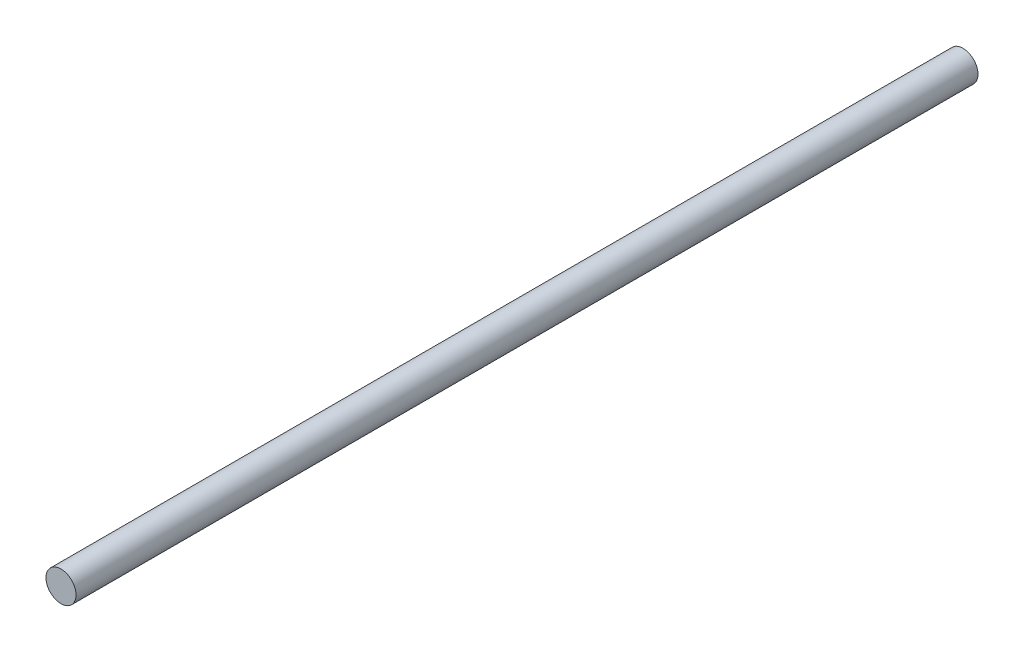
from build123d import *

# Parameters (mm, degrees)
SZKIC1_R                    = 1.5
DODANIE_WYCI_GNI_CIE1_DEPTH = 90


with BuildPart() as part:
    # Szkic1 → Dodanie-wyciągnięcie1 (new body)
    with BuildSketch(Plane.XY):
        Circle(SZKIC1_R)
    extrude(amount=DODANIE_WYCI_GNI_CIE1_DEPTH)


solid = part.part
